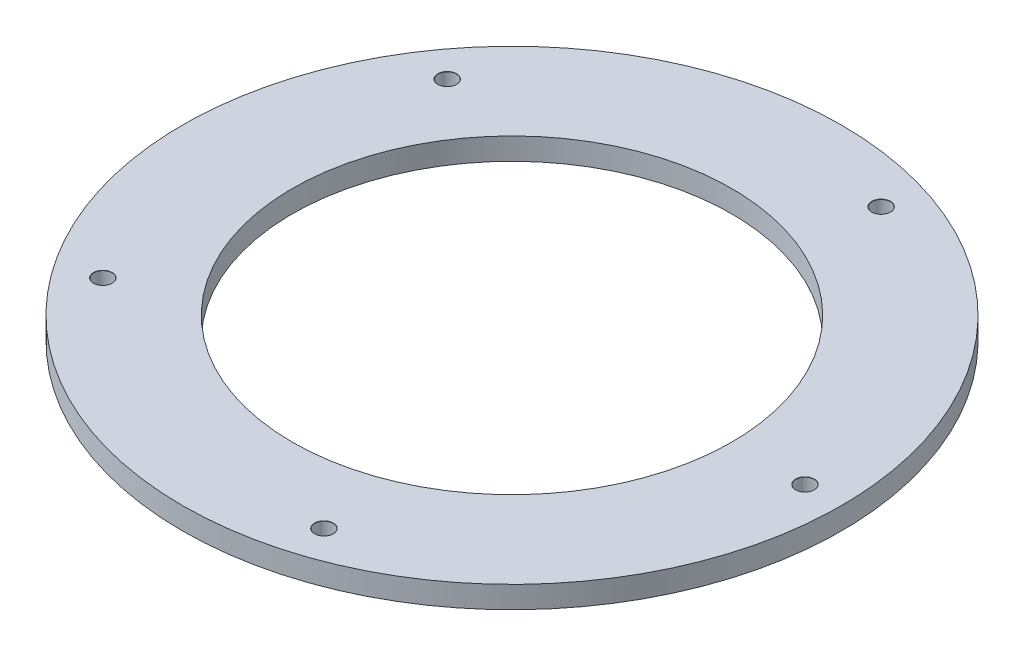
from build123d import *

# Parameters (mm, degrees)
SKETCH_1_R                   = 45
EXTRUDE_1_DEPTH              = 3
SKETCH_5_R                   = 30
CUT_EXTRUDE_1_DEPTH          = 1
CUT_EXTRUDE_1_DEPTH_BACK     = 4
HOLE_WIZARD_M3_2_D           = 2.5
HOLE_WIZARD_M3_2_CSINK_D     = 2.55
HOLE_WIZARD_M3_2_CSINK_ANGLE = 90


with BuildPart() as part:
    # 草图1 → 凸台-拉伸1 (new body)
    with BuildSketch(Plane(origin=(0, 0, 0), x_dir=(1, 0, 0), z_dir=(0, 1, 0))):
        Circle(SKETCH_1_R)
    extrude(amount=EXTRUDE_1_DEPTH)

    # 草图5 → 切除-拉伸1 (cut, two sides)
    with BuildSketch(Plane(origin=(0, 3, 0), x_dir=(1, 0, 0), z_dir=(0, 1, 0))) as cut_extrude_1_sk:
        Circle(SKETCH_5_R)
    extrude(amount=CUT_EXTRUDE_1_DEPTH, mode=Mode.SUBTRACT)
    extrude(cut_extrude_1_sk.sketch, amount=-CUT_EXTRUDE_1_DEPTH_BACK, mode=Mode.SUBTRACT)

    # M3 螺纹孔的螺纹孔钻头2 (through all)
    with Locations(Plane(origin=(0, 3, 0), x_dir=(1, 0, 0), z_dir=(0, 1, 0))):
        with Locations((0, 0), (40, 0), (12.360679775, -38.042260652), (-32.360679775, -23.511410092), (-32.360679775, 23.511410092), (12.360679775, 38.042260652)):
            CounterSinkHole(HOLE_WIZARD_M3_2_D / 2, HOLE_WIZARD_M3_2_CSINK_D / 2, counter_sink_angle=HOLE_WIZARD_M3_2_CSINK_ANGLE)


solid = part.part
